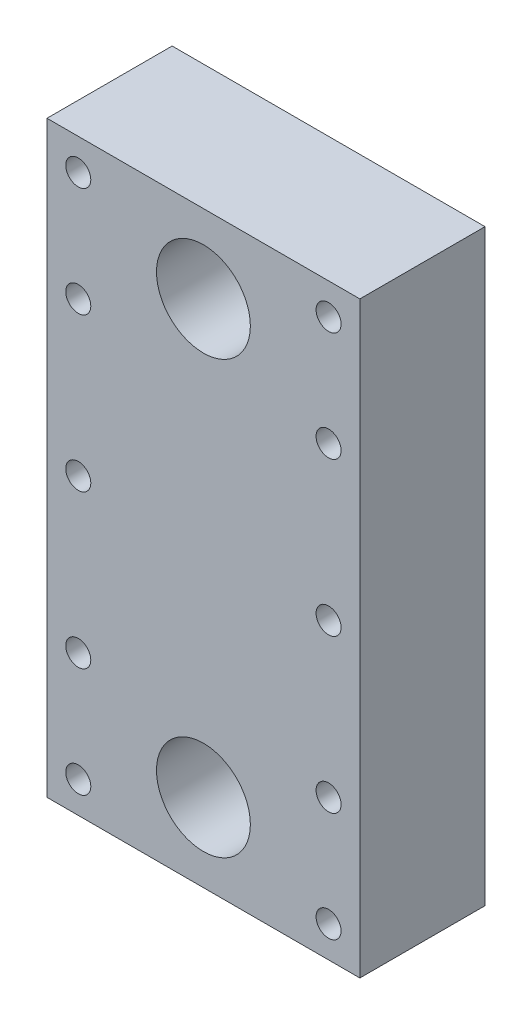
from build123d import *

# Parameters (mm, degrees)
BOSS_EXTRUDE1_DEPTH = 15
CUT_EXTRUDE1_DEPTH  = 16
SKETCH3_W           = 50
SKETCH3_H           = 45
BOSS_EXTRUDE3_DEPTH = 15
SKETCH4_W           = 12.5
SKETCH4_H           = 6.523729489
CUT_EXTRUDE2_DEPTH  = 4
FILLET1_R           = 2
SKETCH5_W           = 50
SKETCH5_H           = 25
SKETCH5_R           = 7.5
BOSS_EXTRUDE4_DEPTH = 15
SKETCH6_R           = 2
CUT_EXTRUDE3_DEPTH  = 16
BOSS_EXTRUDE5_DEPTH = 5
SKETCH8_W           = 50
SKETCH8_H           = 93.984880812
BOSS_EXTRUDE6_DEPTH = 5
SKETCH9_R           = 2
SKETCH9_R_2         = 7.5
CUT_EXTRUDE4_DEPTH  = 21
SKETCH10_R          = 2
CUT_EXTRUDE5_DEPTH  = 21


with BuildPart() as part:
    # Sketch1 → Boss-Extrude1 (new body)
    with BuildSketch(Plane.XY):
        with BuildLine():
            Line((-7, 19), (7, 19))
            ThreePointArc((7, 19), (14.071067812, 16.071067812), (17, 9))
            Line((17, 9), (17, -5))
            ThreePointArc((17, -5), (14.071067812, -12.071067812), (7, -15))
            Line((7, -15), (-7, -15))
            ThreePointArc((-7, -15), (-14.071067812, -12.071067812), (-17, -5))
            Line((-17, -5), (-17, 9))
            ThreePointArc((-17, 9), (-14.071067812, 16.071067812), (-7, 19))
        make_face()
    extrude(amount=BOSS_EXTRUDE1_DEPTH)

    # Sketch2 → Cut-Extrude1 (cut, through all)
    with BuildSketch(Plane(origin=(0, 0, 0), x_dir=(-1, 0, 0), z_dir=(0, 0, -1))):
        with BuildLine():
            Line((14, 0.39), (14, 8.212908396))
            ThreePointArc((14, 8.212908396), (11.719213675, 13.719213675), (6.212908396, 16))
            Line((6.212908396, 16), (-6.212908396, 16))
            ThreePointArc((-6.212908396, 16), (-11.719213675, 13.719213675), (-14, 8.212908396))
            Line((-14, 8.212908396), (-14, 0.39))
            Line((-14, 0.39), (-14, -2.4))
            ThreePointArc((-14, -2.4), (-12.535533906, -5.935533906), (-9, -7.4))
            Line((-9, -7.4), (-8.25, -7.4))
            ThreePointArc((-8.25, -7.4), (-6.835786438, -7.985786438), (-6.25, -9.4))
            Line((-6.25, -9.4), (-6.25, -17.62539529))
            Line((-6.25, -17.62539529), (6.25, -17.62539529))
            Line((6.25, -17.62539529), (6.25, -9.4))
            ThreePointArc((6.25, -9.4), (6.835786438, -7.985786438), (8.25, -7.4))
            Line((8.25, -7.4), (9, -7.4))
            ThreePointArc((9, -7.4), (12.535533906, -5.935533906), (14, -2.4))
            Line((14, -2.4), (14, 0.39))
        make_face()
    extrude(amount=-CUT_EXTRUDE1_DEPTH, mode=Mode.SUBTRACT)

    # Sketch3 → Boss-Extrude3 (add)
    with BuildSketch(Plane(origin=(0, 0, 0), x_dir=(-1, 0, 0), z_dir=(0, 0, -1))):
        with Locations((0, -0.507559594)):
            Rectangle(SKETCH3_W, SKETCH3_H)
        with BuildLine():
            Line((-6.25, -9.4), (-6.25, -15))
            Line((-6.25, -15), (-6.25, -17.5))
            ThreePointArc((-6.25, -17.5), (-5.664213562, -18.914213562), (-4.25, -19.5))
            Line((-4.25, -19.5), (4.25, -19.5))
            ThreePointArc((4.25, -19.5), (5.664213562, -18.914213562), (6.25, -17.5))
            Line((6.25, -17.5), (6.25, -15))
            Line((6.25, -15), (6.25, -9.4))
            ThreePointArc((6.25, -9.4), (6.835786438, -7.985786438), (8.25, -7.4))
            Line((8.25, -7.4), (9, -7.4))
            ThreePointArc((9, -7.4), (12.535533906, -5.935533906), (14, -2.4))
            Line((14, -2.4), (14, 8.212908396))
            ThreePointArc((14, 8.212908396), (11.719213675, 13.719213675), (6.212908396, 16))
            Line((6.212908396, 16), (-6.212908396, 16))
            ThreePointArc((-6.212908396, 16), (-11.719213675, 13.719213675), (-14, 8.212908396))
            Line((-14, 8.212908396), (-14, -2.4))
            ThreePointArc((-14, -2.4), (-12.535533906, -5.935533906), (-9, -7.4))
            Line((-9, -7.4), (-8.25, -7.4))
            ThreePointArc((-8.25, -7.4), (-6.835786438, -7.985786438), (-6.25, -9.4))
        make_face(mode=Mode.SUBTRACT)
    extrude(amount=-BOSS_EXTRUDE3_DEPTH)

    # Sketch4 → Cut-Extrude2 (cut)
    with BuildSketch(Plane(origin=(0, 0, 0), x_dir=(-1, 0, 0), z_dir=(0, 0, -1))):
        with Locations((0, -19.74569485)):
            Rectangle(SKETCH4_W, SKETCH4_H)
    extrude(amount=-CUT_EXTRUDE2_DEPTH, mode=Mode.SUBTRACT)

    # Fillet1
    fillet1_edges = [part.edges().sort_by_distance(p)[0] for p in [
        (6.25, -23.007559594, 2),
        (-6.25, -23.007559594, 2),
    ]]
    fillet(fillet1_edges, radius=FILLET1_R)

    # Sketch5 → Boss-Extrude4 (add)
    with BuildSketch(Plane.XY.offset(15)):
        with Locations((0, 34.492440406)):
            Rectangle(SKETCH5_W, SKETCH5_H)
        with Locations((0, 34.492440406)):
            Circle(SKETCH5_R, mode=Mode.SUBTRACT)
    boss_extrude4 = extrude(amount=-BOSS_EXTRUDE4_DEPTH)

    # Mirror1: Boss-Extrude4 across plane
    add(boss_extrude4.mirror(Plane.ZX))

    # Sketch6 → Cut-Extrude3 (cut, through all)
    with BuildSketch(Plane.XY.offset(15)):
        with Locations((-20, 41.992440406)):
            Circle(SKETCH6_R)
        with Locations((20, 41.992440406)):
            Circle(SKETCH6_R)
        with Locations((20, -41.992440406)):
            Circle(SKETCH6_R)
        with Locations((-20, -41.992440406)):
            Circle(SKETCH6_R)
        with Locations((20, 0)):
            Circle(SKETCH6_R)
        with Locations((-20, 0)):
            Circle(SKETCH6_R)
    extrude(amount=-CUT_EXTRUDE3_DEPTH, mode=Mode.SUBTRACT)

    # Sketch7 → Boss-Extrude5 (add)
    with BuildSketch(Plane.XY.offset(15)):
        with BuildLine():
            Line((-4.25, -19.5), (4.25, -19.5))
            ThreePointArc((4.25, -19.5), (5.664213562, -18.914213562), (6.25, -17.5))
            Line((6.25, -17.5), (6.25, -9.4))
            ThreePointArc((6.25, -9.4), (6.835786438, -7.985786438), (8.25, -7.4))
            Line((8.25, -7.4), (9, -7.4))
            ThreePointArc((9, -7.4), (12.535533906, -5.935533906), (14, -2.4))
            Line((14, -2.4), (14, 8.212908396))
            ThreePointArc((14, 8.212908396), (11.719213675, 13.719213675), (6.212908396, 16))
            Line((6.212908396, 16), (-6.212908396, 16))
            ThreePointArc((-6.212908396, 16), (-11.719213675, 13.719213675), (-14, 8.212908396))
            Line((-14, 8.212908396), (-14, -2.4))
            ThreePointArc((-14, -2.4), (-12.535533906, -5.935533906), (-9, -7.4))
            Line((-9, -7.4), (-8.25, -7.4))
            ThreePointArc((-8.25, -7.4), (-6.835786438, -7.985786438), (-6.25, -9.4))
            Line((-6.25, -9.4), (-6.25, -17.5))
            ThreePointArc((-6.25, -17.5), (-5.664213562, -18.914213562), (-4.25, -19.5))
        make_face()
    extrude(amount=-BOSS_EXTRUDE5_DEPTH)

    # Sketch8 → Boss-Extrude6 (add)
    with BuildSketch(Plane.XY.offset(15)):
        Rectangle(SKETCH8_W, SKETCH8_H)
    extrude(amount=BOSS_EXTRUDE6_DEPTH)

    # Sketch9 → Cut-Extrude4 (cut, through all)
    with BuildSketch(Plane(origin=(0, 0, 0), x_dir=(-1, 0, 0), z_dir=(0, 0, -1))):
        with Locations((20, -41.992440406)):
            Circle(SKETCH9_R)
        with Locations((0, -34.492440406)):
            Circle(SKETCH9_R_2)
        with Locations((-20, -41.992440406)):
            Circle(SKETCH9_R)
        with Locations((20, 0)):
            Circle(SKETCH9_R)
        with Locations((-20, 0)):
            Circle(SKETCH9_R)
        with Locations((-20, 41.992440406)):
            Circle(SKETCH9_R)
        with Locations((0, 34.492440406)):
            Circle(SKETCH9_R_2)
        with Locations((20, 41.992440406)):
            Circle(SKETCH9_R)
    extrude(amount=-CUT_EXTRUDE4_DEPTH, mode=Mode.SUBTRACT)

    # Sketch10 → Cut-Extrude5 (cut, through all)
    with BuildSketch(Plane.XY.offset(20)):
        with Locations((-20, 24.492440406)):
            Circle(SKETCH10_R)
        with Locations((20, 24.492440406)):
            Circle(SKETCH10_R)
        with Locations((20, -24.492440406)):
            Circle(SKETCH10_R)
        with Locations((-20, -24.492440406)):
            Circle(SKETCH10_R)
    extrude(amount=-CUT_EXTRUDE5_DEPTH, mode=Mode.SUBTRACT)


solid = part.part
